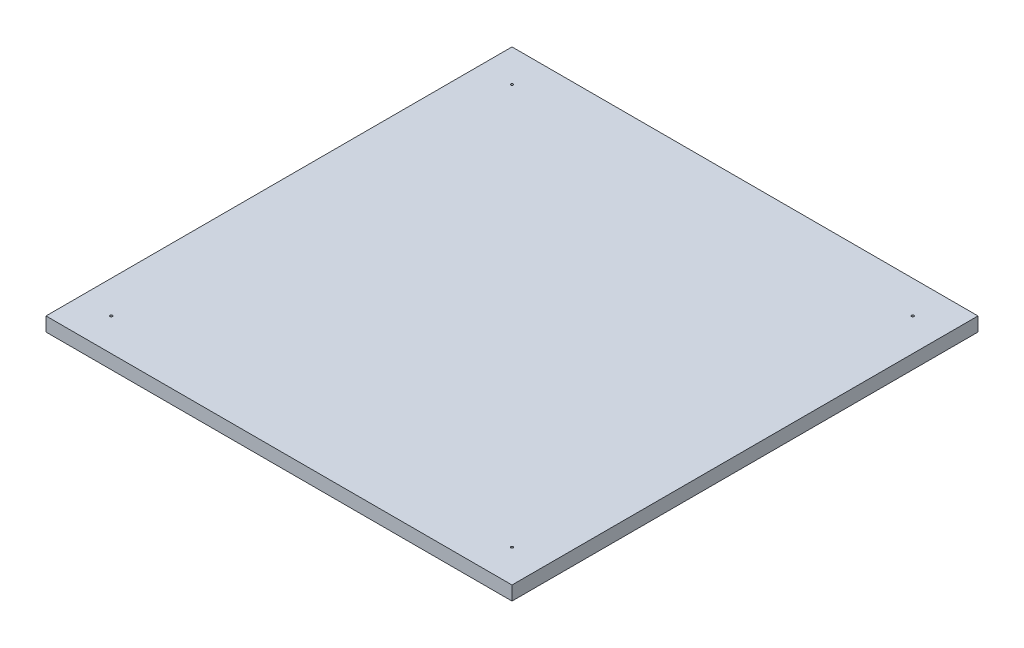
from build123d import *

# Parameters (mm, degrees)
SKETCH1_W           = 1000
SKETCH1_H           = 30
BOSS_EXTRUDE1_DEPTH = 500
SKETCH2_R           = 2.5
CUT_EXTRUDE2_DEPTH  = 5


with BuildPart() as part:
    # Sketch1 → Boss-Extrude1 (new body, symmetric)
    with BuildSketch(Plane(origin=(0, 0, 0), x_dir=(0, 0, -1), z_dir=(1, 0, 0))):
        with Locations((500, 15)):
            Rectangle(SKETCH1_W, SKETCH1_H)
    extrude(amount=BOSS_EXTRUDE1_DEPTH, both=True)

    # Sketch2 → Cut-Extrude2 (cut)
    with BuildSketch(Plane(origin=(0, 30, 0), x_dir=(1, 0, 0), z_dir=(0, 1, 0))):
        with Locations((-430, 70)):
            Circle(SKETCH2_R)
        with Locations((-430, 930)):
            Circle(SKETCH2_R)
        with Locations((430, 930)):
            Circle(SKETCH2_R)
        with Locations((430, 70)):
            Circle(SKETCH2_R)
    extrude(amount=-CUT_EXTRUDE2_DEPTH, mode=Mode.SUBTRACT)


solid = part.part
